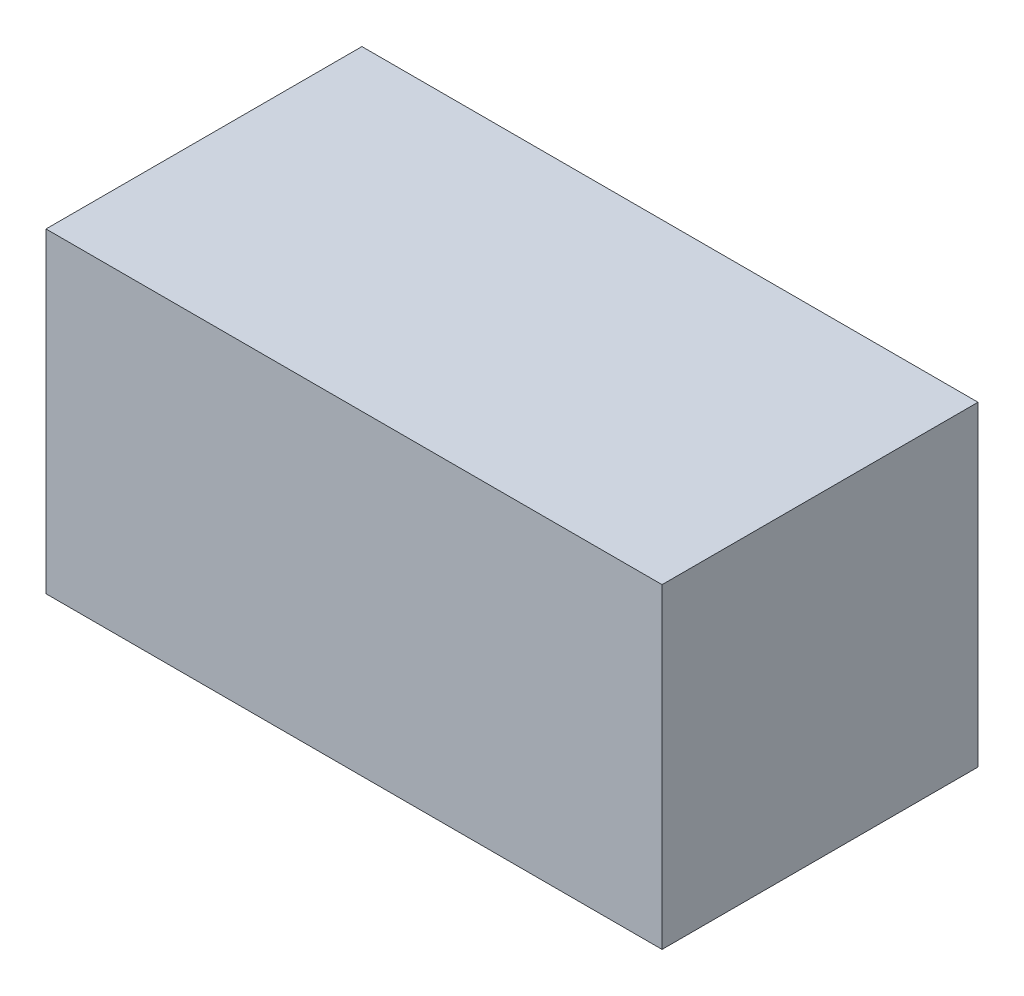
from build123d import *

# Parameters (mm, degrees)
SKETCH1_W           = 975
SKETCH1_H           = 500
BOSS_EXTRUDE1_DEPTH = 500


with BuildPart() as part:
    # Sketch1 → Boss-Extrude1 (new body)
    with BuildSketch(Plane(origin=(0, 0, 0), x_dir=(1, 0, 0), z_dir=(0, 1, 0))):
        Rectangle(SKETCH1_W, SKETCH1_H)
    extrude(amount=BOSS_EXTRUDE1_DEPTH)


solid = part.part
